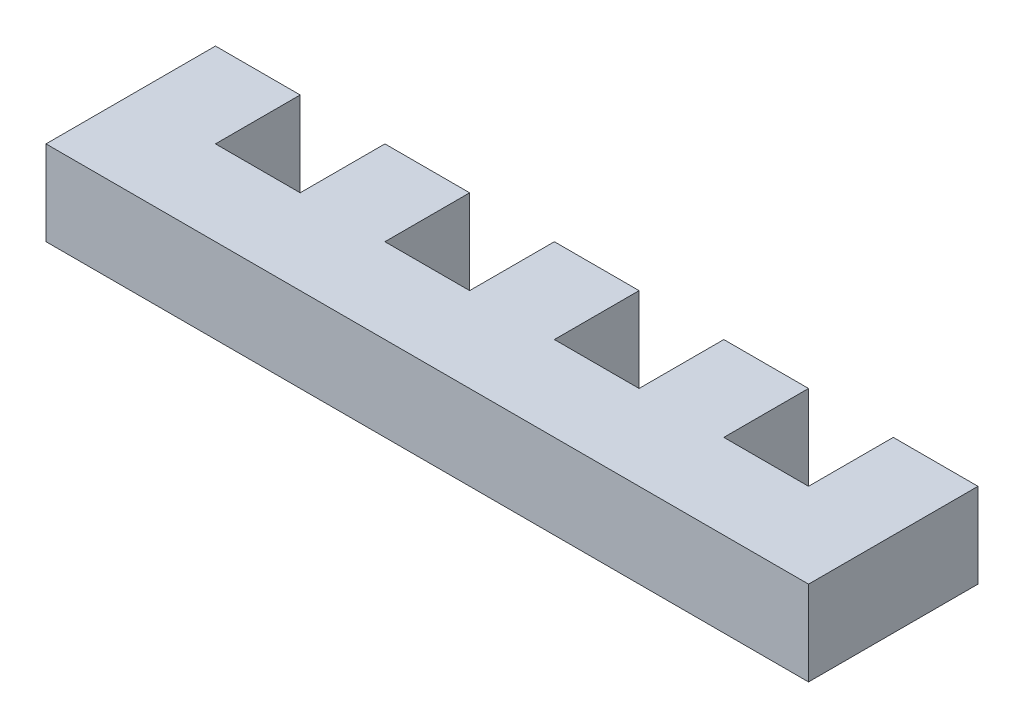
from build123d import *

# Parameters (mm, degrees)
BOSS_EXTRUDE1_DEPTH = 6.35


with BuildPart() as part:
    # Sketch1 → Boss-Extrude1 (new body)
    with BuildSketch(Plane(origin=(0, 0, 0), x_dir=(1, 0, 0), z_dir=(0, 1, 0))):
        Polygon((0, 12.7), (0, 0), (57.15, 0), (57.15, 12.7), (50.8, 12.7), (50.8, 6.35), (44.45, 6.35), (44.45, 12.7), (38.1, 12.7), (38.1, 6.35), (31.75, 6.35), (31.75, 12.7), (25.4, 12.7), (25.4, 6.35), (19.05, 6.35), (19.05, 12.7), (12.7, 12.7), (12.7, 6.35), (6.35, 6.35), (6.35, 12.7), align=None)
    extrude(amount=BOSS_EXTRUDE1_DEPTH)


solid = part.part
